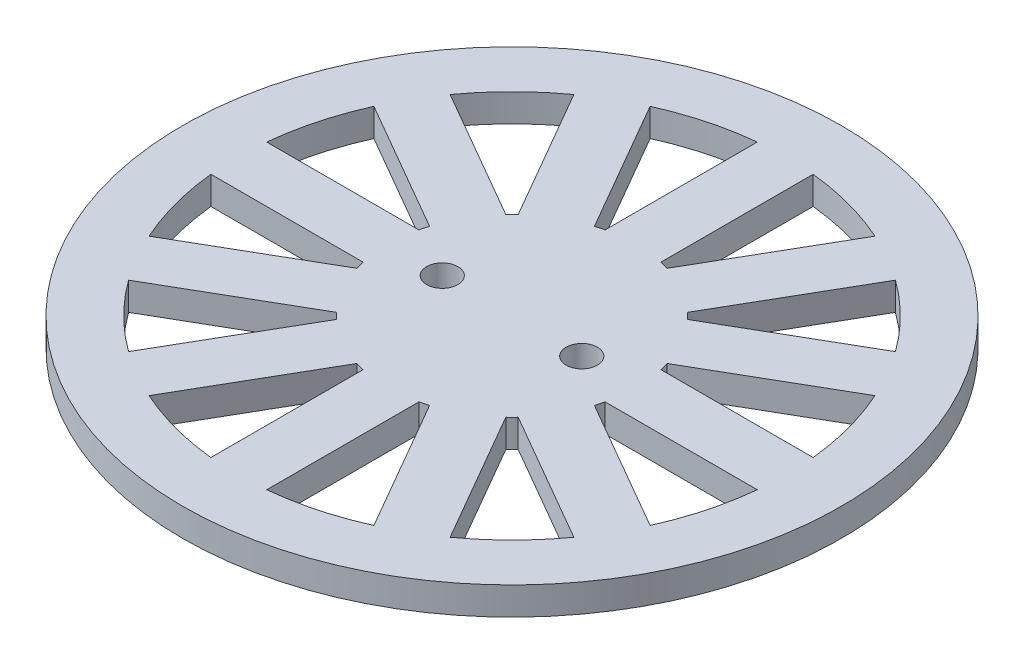
from build123d import *

# Parameters (mm, degrees)
SKETCH1_R           = 30
SKETCH1_R_2         = 1.4224
BOSS_EXTRUDE1_DEPTH = 2.54


with BuildPart() as part:
    # Sketch1 → Boss-Extrude1 (new body)
    with BuildSketch(Plane(origin=(0, 0, 0), x_dir=(1, 0, 0), z_dir=(0, 1, 0))):
        Circle(SKETCH1_R)
        with BuildLine():
            ThreePointArc((3.308860999, 10.811115366), (2.926244071, 10.920891548), (2.54, 11.01713105))
            Line((2.54, 11.01713105), (2.54, 24.870633323))
            ThreePointArc((2.54, 24.870633323), (6.470476137, 24.148145694), (10.235612136, 22.808600266))
            Line((10.235612136, 22.808600266), (3.308860999, 10.811115366))
        make_face(mode=Mode.SUBTRACT)
        with BuildLine():
            ThreePointArc((8.271115366, 7.708270051), (7.994647477, 7.994647477), (7.708270051, 8.271115366))
            Line((7.708270051, 8.271115366), (14.635021187, 20.268600266))
            ThreePointArc((14.635021187, 20.268600266), (17.677669557, 17.677669557), (20.268600266, 14.635021187))
            Line((20.268600266, 14.635021187), (8.271115366, 7.708270051))
        make_face(mode=Mode.SUBTRACT)
        with BuildLine():
            ThreePointArc((11.01713105, 2.54), (10.920891548, 2.926244071), (10.811115366, 3.308860999))
            Line((10.811115366, 3.308860999), (22.808600266, 10.235612136))
            ThreePointArc((22.808600266, 10.235612136), (24.148145694, 6.470476137), (24.870633323, 2.54))
            Line((24.870633323, 2.54), (11.01713105, 2.54))
        make_face(mode=Mode.SUBTRACT)
        with BuildLine():
            ThreePointArc((10.811115366, -3.308860999), (10.920891548, -2.926244071), (11.01713105, -2.54))
            Line((11.01713105, -2.54), (24.870633323, -2.54))
            ThreePointArc((24.870633323, -2.54), (24.148145694, -6.470476137), (22.808600266, -10.235612136))
            Line((22.808600266, -10.235612136), (10.811115366, -3.308860999))
        make_face(mode=Mode.SUBTRACT)
        with BuildLine():
            ThreePointArc((7.708270051, -8.271115366), (7.994647477, -7.994647477), (8.271115366, -7.708270051))
            Line((8.271115366, -7.708270051), (20.268600266, -14.635021187))
            ThreePointArc((20.268600266, -14.635021187), (17.677669557, -17.677669557), (14.635021187, -20.268600266))
            Line((14.635021187, -20.268600266), (7.708270051, -8.271115366))
        make_face(mode=Mode.SUBTRACT)
        with BuildLine():
            ThreePointArc((2.54, -11.01713105), (2.926244071, -10.920891548), (3.308860999, -10.811115366))
            Line((3.308860999, -10.811115366), (10.235612136, -22.808600266))
            ThreePointArc((10.235612136, -22.808600266), (6.470476137, -24.148145694), (2.54, -24.870633323))
            Line((2.54, -24.870633323), (2.54, -11.01713105))
        make_face(mode=Mode.SUBTRACT)
        with BuildLine():
            ThreePointArc((-3.308860999, -10.811115366), (-2.926244071, -10.920891548), (-2.54, -11.01713105))
            Line((-2.54, -11.01713105), (-2.54, -24.870633323))
            ThreePointArc((-2.54, -24.870633323), (-6.470476137, -24.148145694), (-10.235612136, -22.808600266))
            Line((-10.235612136, -22.808600266), (-3.308860999, -10.811115366))
        make_face(mode=Mode.SUBTRACT)
        with BuildLine():
            ThreePointArc((-8.271115366, -7.708270051), (-7.994647477, -7.994647477), (-7.708270051, -8.271115366))
            Line((-7.708270051, -8.271115366), (-14.635021187, -20.268600266))
            ThreePointArc((-14.635021187, -20.268600266), (-17.677669557, -17.677669557), (-20.268600266, -14.635021187))
            Line((-20.268600266, -14.635021187), (-8.271115366, -7.708270051))
        make_face(mode=Mode.SUBTRACT)
        with BuildLine():
            ThreePointArc((-11.01713105, -2.54), (-10.920891548, -2.926244071), (-10.811115366, -3.308860999))
            Line((-10.811115366, -3.308860999), (-22.808600266, -10.235612136))
            ThreePointArc((-22.808600266, -10.235612136), (-24.148145694, -6.470476137), (-24.870633323, -2.54))
            Line((-24.870633323, -2.54), (-11.01713105, -2.54))
        make_face(mode=Mode.SUBTRACT)
        with BuildLine():
            ThreePointArc((-10.811115366, 3.308860999), (-10.920891548, 2.926244071), (-11.01713105, 2.54))
            Line((-11.01713105, 2.54), (-24.870633323, 2.54))
            ThreePointArc((-24.870633323, 2.54), (-24.148145694, 6.470476137), (-22.808600266, 10.235612136))
            Line((-22.808600266, 10.235612136), (-10.811115366, 3.308860999))
        make_face(mode=Mode.SUBTRACT)
        with BuildLine():
            ThreePointArc((-7.708270051, 8.271115366), (-7.994647477, 7.994647477), (-8.271115366, 7.708270051))
            Line((-8.271115366, 7.708270051), (-20.268600266, 14.635021187))
            ThreePointArc((-20.268600266, 14.635021187), (-17.677669557, 17.677669557), (-14.635021187, 20.268600266))
            Line((-14.635021187, 20.268600266), (-7.708270051, 8.271115366))
        make_face(mode=Mode.SUBTRACT)
        with BuildLine():
            ThreePointArc((-2.54, 11.01713105), (-2.926244071, 10.920891548), (-3.308860999, 10.811115366))
            Line((-3.308860999, 10.811115366), (-10.235612136, 22.808600266))
            ThreePointArc((-10.235612136, 22.808600266), (-6.470476137, 24.148145694), (-2.54, 24.870633323))
            Line((-2.54, 24.870633323), (-2.54, 11.01713105))
        make_face(mode=Mode.SUBTRACT)
        with Locations((-6.35, 0)):
            Circle(SKETCH1_R_2, mode=Mode.SUBTRACT)
        with Locations((6.35, 0)):
            Circle(SKETCH1_R_2, mode=Mode.SUBTRACT)
    extrude(amount=BOSS_EXTRUDE1_DEPTH)


solid = part.part
